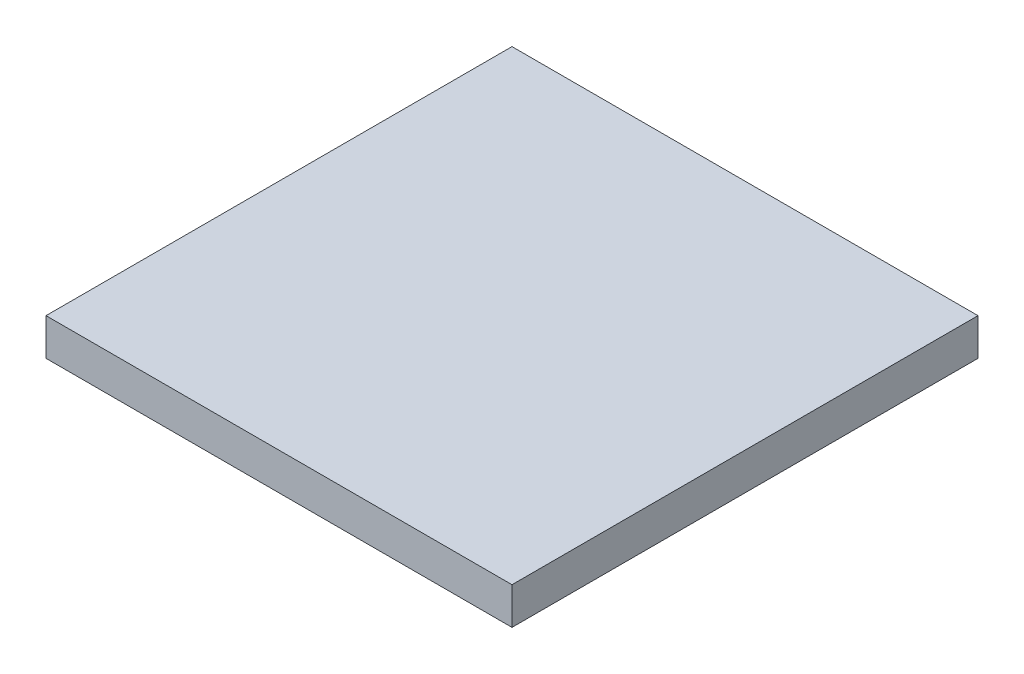
from build123d import *

# Parameters (mm, degrees)
SKETCH2_W           = 40
SKETCH2_H           = 40
BOSS_EXTRUDE1_DEPTH = 3.175


with BuildPart() as part:
    # Sketch2 → Boss-Extrude1 (new body)
    with BuildSketch(Plane(origin=(0, 0, 0), x_dir=(1, 0, 0), z_dir=(0, 1, 0))):
        with Locations((-30.089526354, -25.165471221)):
            Rectangle(SKETCH2_W, SKETCH2_H)
    extrude(amount=BOSS_EXTRUDE1_DEPTH)


solid = part.part
